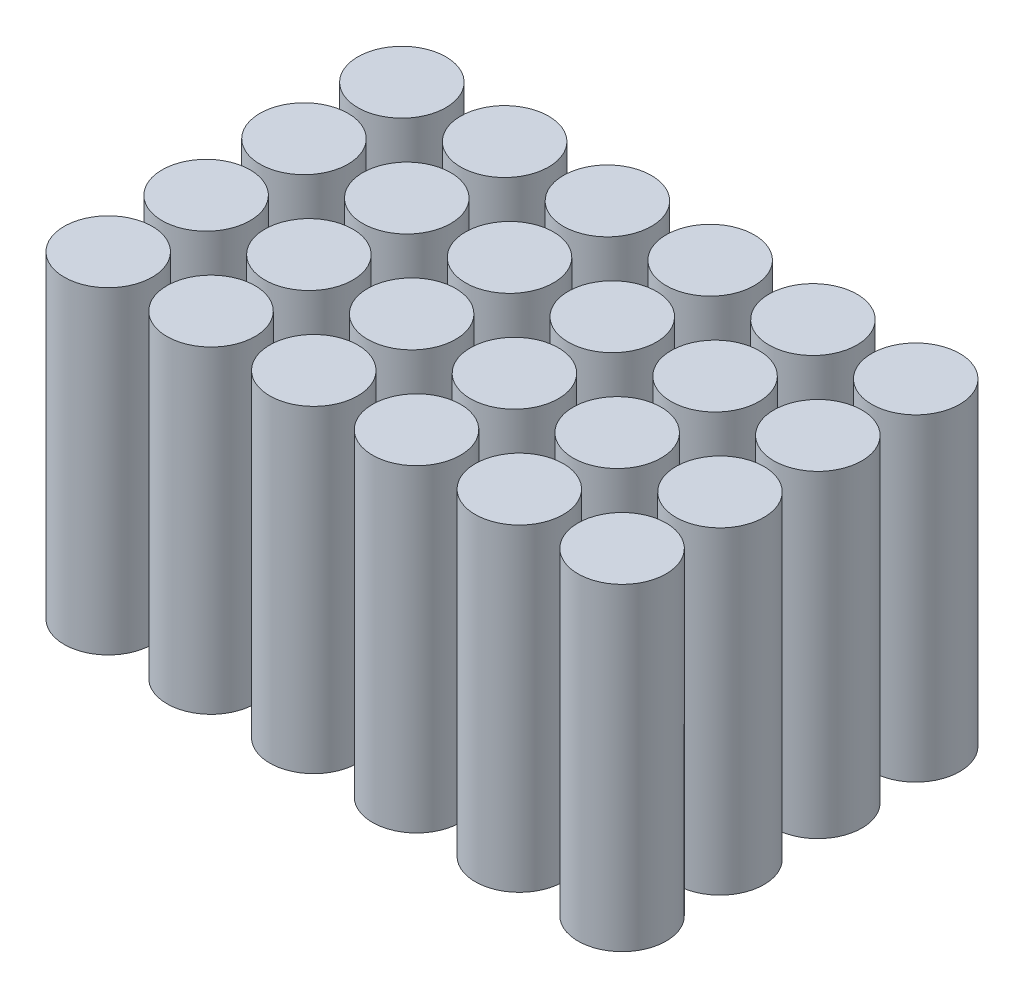
from build123d import *

# Parameters (mm, degrees)
SKETCH2_R              = 9
BOSS_EXTRUDE1_DEPTH    = 65
BOSS_EXTRUDE1_2_DEPTH  = 65
BOSS_EXTRUDE1_3_DEPTH  = 65
BOSS_EXTRUDE1_4_DEPTH  = 65
BOSS_EXTRUDE1_5_DEPTH  = 65
BOSS_EXTRUDE1_6_DEPTH  = 65
BOSS_EXTRUDE1_7_DEPTH  = 65
BOSS_EXTRUDE1_8_DEPTH  = 65
BOSS_EXTRUDE1_9_DEPTH  = 65
BOSS_EXTRUDE1_10_DEPTH = 65
BOSS_EXTRUDE1_11_DEPTH = 65
BOSS_EXTRUDE1_12_DEPTH = 65
BOSS_EXTRUDE1_13_DEPTH = 65
BOSS_EXTRUDE1_14_DEPTH = 65
BOSS_EXTRUDE1_15_DEPTH = 65
BOSS_EXTRUDE1_16_DEPTH = 65
BOSS_EXTRUDE1_17_DEPTH = 65
BOSS_EXTRUDE1_18_DEPTH = 65
BOSS_EXTRUDE1_19_DEPTH = 65
BOSS_EXTRUDE1_20_DEPTH = 65
BOSS_EXTRUDE1_21_DEPTH = 65
BOSS_EXTRUDE1_22_DEPTH = 65
BOSS_EXTRUDE1_23_DEPTH = 65
BOSS_EXTRUDE1_24_DEPTH = 65


with BuildPart() as part:
    # Sketch2 → Boss-Extrude1 (new body)
    with BuildSketch(Plane(origin=(0, 0, 0), x_dir=(1, 0, 0), z_dir=(0, 1, 0))):
        with Locations((-10.5, -10)):
            Circle(SKETCH2_R)
    extrude(amount=BOSS_EXTRUDE1_DEPTH)


with BuildPart() as body_2:
    # Sketch2 → Boss-Extrude1 2 (new body)
    with BuildSketch(Plane(origin=(0, 0, 0), x_dir=(1, 0, 0), z_dir=(0, 1, 0))):
        with Locations((10.5, -10)):
            Circle(SKETCH2_R)
    extrude(amount=BOSS_EXTRUDE1_2_DEPTH)


with BuildPart() as body_3:
    # Sketch2 → Boss-Extrude1 3 (new body)
    with BuildSketch(Plane(origin=(0, 0, 0), x_dir=(1, 0, 0), z_dir=(0, 1, 0))):
        with Locations((31.5, -10)):
            Circle(SKETCH2_R)
    extrude(amount=BOSS_EXTRUDE1_3_DEPTH)


with BuildPart() as body_4:
    # Sketch2 → Boss-Extrude1 4 (new body)
    with BuildSketch(Plane(origin=(0, 0, 0), x_dir=(1, 0, 0), z_dir=(0, 1, 0))):
        with Locations((52.5, -10)):
            Circle(SKETCH2_R)
    extrude(amount=BOSS_EXTRUDE1_4_DEPTH)


with BuildPart() as body_5:
    # Sketch2 → Boss-Extrude1 5 (new body)
    with BuildSketch(Plane(origin=(0, 0, 0), x_dir=(1, 0, 0), z_dir=(0, 1, 0))):
        with Locations((10.5, 10)):
            Circle(SKETCH2_R)
    extrude(amount=BOSS_EXTRUDE1_5_DEPTH)


with BuildPart() as body_6:
    # Sketch2 → Boss-Extrude1 6 (new body)
    with BuildSketch(Plane(origin=(0, 0, 0), x_dir=(1, 0, 0), z_dir=(0, 1, 0))):
        with Locations((31.5, 10)):
            Circle(SKETCH2_R)
    extrude(amount=BOSS_EXTRUDE1_6_DEPTH)


with BuildPart() as body_7:
    # Sketch2 → Boss-Extrude1 7 (new body)
    with BuildSketch(Plane(origin=(0, 0, 0), x_dir=(1, 0, 0), z_dir=(0, 1, 0))):
        with Locations((52.5, 10)):
            Circle(SKETCH2_R)
    extrude(amount=BOSS_EXTRUDE1_7_DEPTH)


with BuildPart() as body_8:
    # Sketch2 → Boss-Extrude1 8 (new body)
    with BuildSketch(Plane(origin=(0, 0, 0), x_dir=(1, 0, 0), z_dir=(0, 1, 0))):
        with Locations((10.5, 30)):
            Circle(SKETCH2_R)
    extrude(amount=BOSS_EXTRUDE1_8_DEPTH)


with BuildPart() as body_9:
    # Sketch2 → Boss-Extrude1 9 (new body)
    with BuildSketch(Plane(origin=(0, 0, 0), x_dir=(1, 0, 0), z_dir=(0, 1, 0))):
        with Locations((31.5, 30)):
            Circle(SKETCH2_R)
    extrude(amount=BOSS_EXTRUDE1_9_DEPTH)


with BuildPart() as body_10:
    # Sketch2 → Boss-Extrude1 10 (new body)
    with BuildSketch(Plane(origin=(0, 0, 0), x_dir=(1, 0, 0), z_dir=(0, 1, 0))):
        with Locations((52.5, 30)):
            Circle(SKETCH2_R)
    extrude(amount=BOSS_EXTRUDE1_10_DEPTH)


with BuildPart() as body_11:
    # Sketch2 → Boss-Extrude1 11 (new body)
    with BuildSketch(Plane(origin=(0, 0, 0), x_dir=(1, 0, 0), z_dir=(0, 1, 0))):
        with Locations((-10.5, 10)):
            Circle(SKETCH2_R)
    extrude(amount=BOSS_EXTRUDE1_11_DEPTH)


with BuildPart() as body_12:
    # Sketch2 → Boss-Extrude1 12 (new body)
    with BuildSketch(Plane(origin=(0, 0, 0), x_dir=(1, 0, 0), z_dir=(0, 1, 0))):
        with Locations((-10.5, 30)):
            Circle(SKETCH2_R)
    extrude(amount=BOSS_EXTRUDE1_12_DEPTH)


with BuildPart() as body_13:
    # Sketch2 → Boss-Extrude1 13 (new body)
    with BuildSketch(Plane(origin=(0, 0, 0), x_dir=(1, 0, 0), z_dir=(0, 1, 0))):
        with Locations((-10.5, -30)):
            Circle(SKETCH2_R)
    extrude(amount=BOSS_EXTRUDE1_13_DEPTH)


with BuildPart() as body_14:
    # Sketch2 → Boss-Extrude1 14 (new body)
    with BuildSketch(Plane(origin=(0, 0, 0), x_dir=(1, 0, 0), z_dir=(0, 1, 0))):
        with Locations((52.5, -30)):
            Circle(SKETCH2_R)
    extrude(amount=BOSS_EXTRUDE1_14_DEPTH)


with BuildPart() as body_15:
    # Sketch2 → Boss-Extrude1 15 (new body)
    with BuildSketch(Plane(origin=(0, 0, 0), x_dir=(1, 0, 0), z_dir=(0, 1, 0))):
        with Locations((31.5, -30)):
            Circle(SKETCH2_R)
    extrude(amount=BOSS_EXTRUDE1_15_DEPTH)


with BuildPart() as body_16:
    # Sketch2 → Boss-Extrude1 16 (new body)
    with BuildSketch(Plane(origin=(0, 0, 0), x_dir=(1, 0, 0), z_dir=(0, 1, 0))):
        with Locations((10.5, -30)):
            Circle(SKETCH2_R)
    extrude(amount=BOSS_EXTRUDE1_16_DEPTH)


with BuildPart() as body_17:
    # Sketch2 → Boss-Extrude1 17 (new body)
    with BuildSketch(Plane(origin=(0, 0, 0), x_dir=(1, 0, 0), z_dir=(0, 1, 0))):
        with Locations((-52.5, -30)):
            Circle(SKETCH2_R)
    extrude(amount=BOSS_EXTRUDE1_17_DEPTH)


with BuildPart() as body_18:
    # Sketch2 → Boss-Extrude1 18 (new body)
    with BuildSketch(Plane(origin=(0, 0, 0), x_dir=(1, 0, 0), z_dir=(0, 1, 0))):
        with Locations((-52.5, -10)):
            Circle(SKETCH2_R)
    extrude(amount=BOSS_EXTRUDE1_18_DEPTH)


with BuildPart() as body_19:
    # Sketch2 → Boss-Extrude1 19 (new body)
    with BuildSketch(Plane(origin=(0, 0, 0), x_dir=(1, 0, 0), z_dir=(0, 1, 0))):
        with Locations((-52.5, 10)):
            Circle(SKETCH2_R)
    extrude(amount=BOSS_EXTRUDE1_19_DEPTH)


with BuildPart() as body_20:
    # Sketch2 → Boss-Extrude1 20 (new body)
    with BuildSketch(Plane(origin=(0, 0, 0), x_dir=(1, 0, 0), z_dir=(0, 1, 0))):
        with Locations((-52.5, 30)):
            Circle(SKETCH2_R)
    extrude(amount=BOSS_EXTRUDE1_20_DEPTH)


with BuildPart() as body_21:
    # Sketch2 → Boss-Extrude1 21 (new body)
    with BuildSketch(Plane(origin=(0, 0, 0), x_dir=(1, 0, 0), z_dir=(0, 1, 0))):
        with Locations((-31.5, -30)):
            Circle(SKETCH2_R)
    extrude(amount=BOSS_EXTRUDE1_21_DEPTH)


with BuildPart() as body_22:
    # Sketch2 → Boss-Extrude1 22 (new body)
    with BuildSketch(Plane(origin=(0, 0, 0), x_dir=(1, 0, 0), z_dir=(0, 1, 0))):
        with Locations((-31.5, -10)):
            Circle(SKETCH2_R)
    extrude(amount=BOSS_EXTRUDE1_22_DEPTH)


with BuildPart() as body_23:
    # Sketch2 → Boss-Extrude1 23 (new body)
    with BuildSketch(Plane(origin=(0, 0, 0), x_dir=(1, 0, 0), z_dir=(0, 1, 0))):
        with Locations((-31.5, 10)):
            Circle(SKETCH2_R)
    extrude(amount=BOSS_EXTRUDE1_23_DEPTH)


with BuildPart() as body_24:
    # Sketch2 → Boss-Extrude1 24 (new body)
    with BuildSketch(Plane(origin=(0, 0, 0), x_dir=(1, 0, 0), z_dir=(0, 1, 0))):
        with Locations((-31.5, 30)):
            Circle(SKETCH2_R)
    extrude(amount=BOSS_EXTRUDE1_24_DEPTH)


solid = Compound([part.part, body_2.part, body_3.part, body_4.part, body_5.part, body_6.part, body_7.part, body_8.part, body_9.part, body_10.part, body_11.part, body_12.part, body_13.part, body_14.part, body_15.part, body_16.part, body_17.part, body_18.part, body_19.part, body_20.part, body_21.part, body_22.part, body_23.part, body_24.part])
